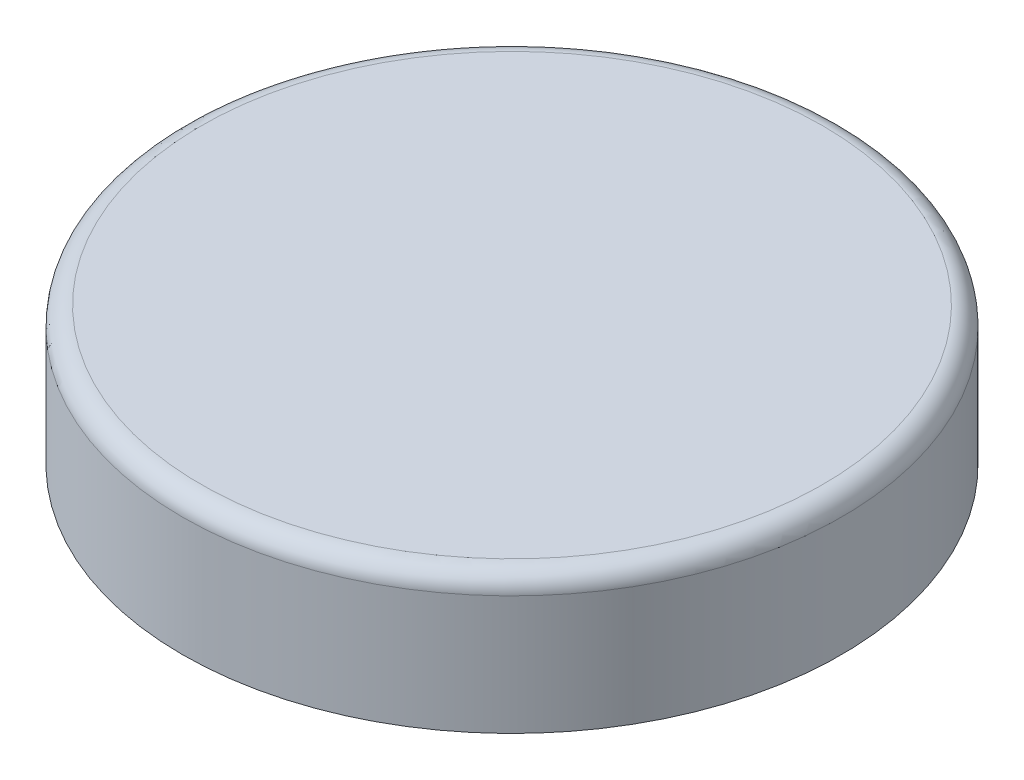
from build123d import *

# Parameters (mm, degrees)
SKETCH1_W = 166.8859375
SKETCH1_H = 69.85
FILLET1_R = 9.525
SHELL1_T  = -4.7625


with BuildPart() as part:
    # Sketch1 → Revolve1 (revolve)
    with BuildSketch(Plane(origin=(0, 0, 0), x_dir=(0, 0, -1), z_dir=(1, 0, 0)), mode=Mode.PRIVATE) as revolve1_sk:
        with Locations((-83.44296875, 34.925)):
            Rectangle(SKETCH1_W, SKETCH1_H)
    revolve(revolve1_sk.sketch.rotate(Axis((0, 0, 0), (0, 1, 0)), 180), axis=Axis((0, 0, 0), (0, 1, 0)))

    # Fillet1
    fillet1_edges = [part.edges().sort_by_distance(p)[0] for p in [
        (0, 69.85, 166.8859375),
    ]]
    fillet(fillet1_edges, radius=FILLET1_R)

    # Shell1
    shell1_openings = [part.faces().sort_by_distance(p)[0] for p in [
        (0, 0, 0),
    ]]
    offset(amount=SHELL1_T, openings=shell1_openings, kind=Kind.INTERSECTION)


solid = part.part
